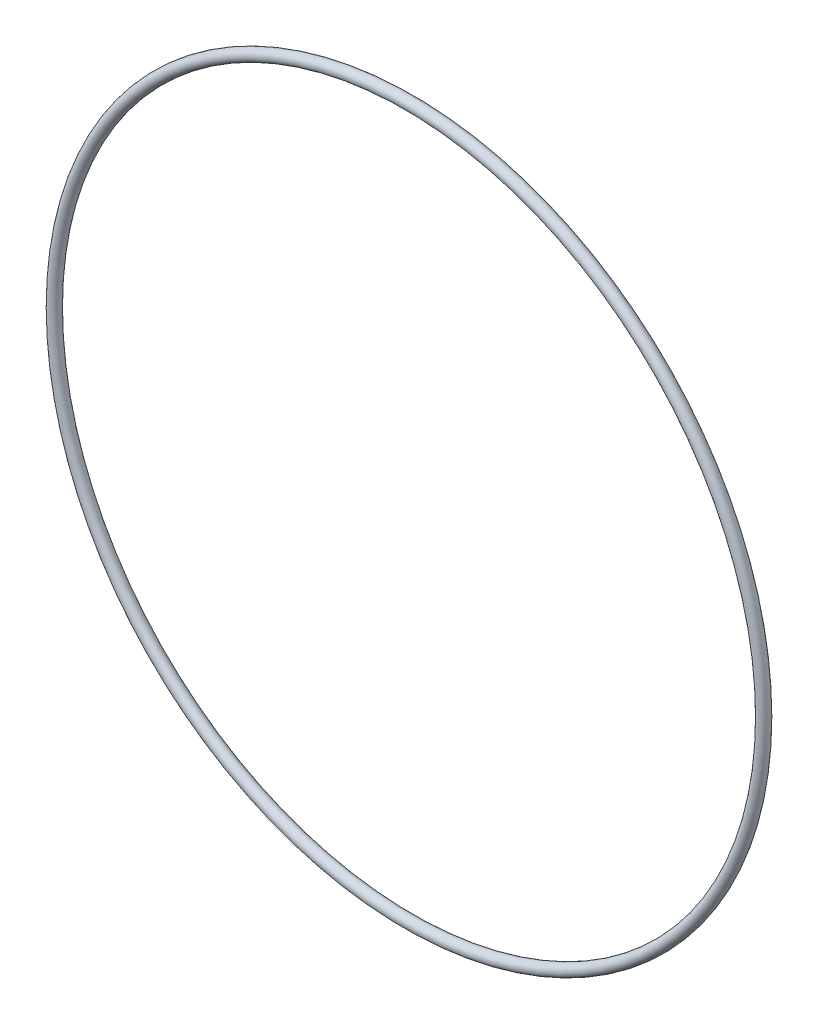
from build123d import *

# Parameters (mm, degrees)
SKETCH1_R = 0.889


with BuildPart() as part:
    # Sketch1 → Revolve1 (revolve)
    with BuildSketch(Plane(origin=(0, 0, 0), x_dir=(0, -1, 0), z_dir=(1, 0, 0))):
        with Locations((54.7243, 0)):
            Circle(SKETCH1_R)
    revolve(axis=Axis((0, 0, 0.889), (0, 0, -1)))


solid = part.part
